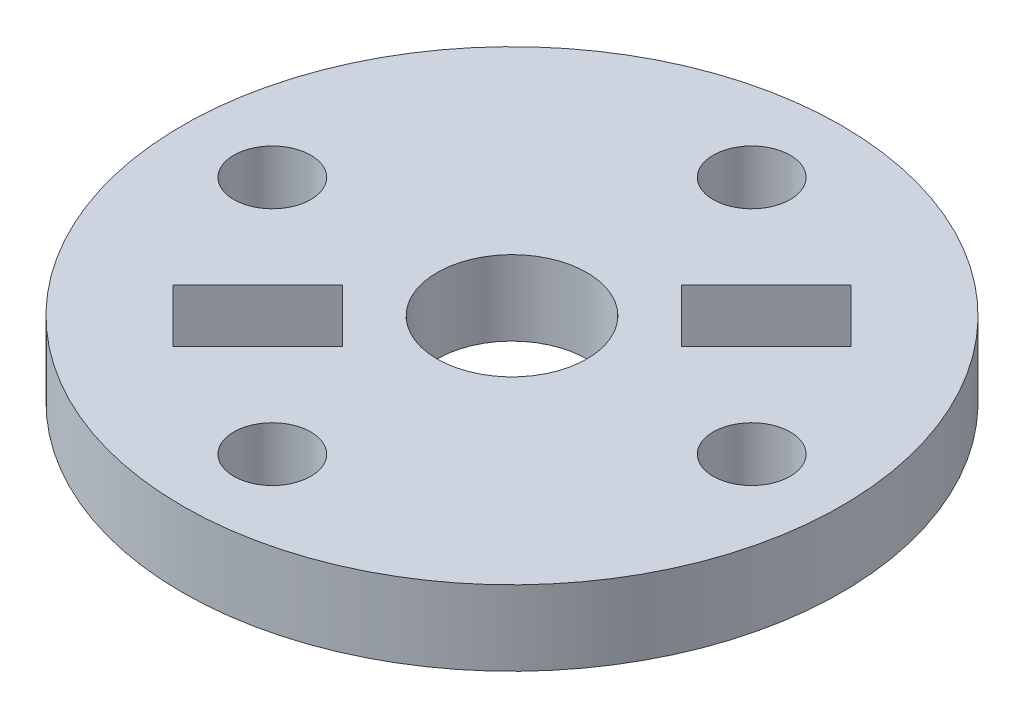
from build123d import *

# Parameters (mm, degrees)
SKETCH1_R           = 13.97
BOSS_EXTRUDE1_DEPTH = 3.175
SKETCH2_R           = 3.175
CUT_EXTRUDE1_DEPTH  = 3.175
CIRPATTERN1_COUNT   = 4
CUT_EXTRUDE2_DEPTH  = 5.08
CIRPATTERN2_COUNT   = 2


with BuildPart() as part:
    # Sketch1 → Boss-Extrude1 (new body)
    with BuildSketch(Plane(origin=(0, 0, 0), x_dir=(1, 0, 0), z_dir=(0, 1, 0))):
        Circle(SKETCH1_R)
    extrude(amount=BOSS_EXTRUDE1_DEPTH)

    # Sketch2 → Cut-Extrude1 (cut)
    with BuildSketch(Plane(origin=(0, 3.175, 0), x_dir=(1, 0, 0), z_dir=(0, 1, 0))):
        Circle(SKETCH2_R)
    extrude(amount=-CUT_EXTRUDE1_DEPTH, mode=Mode.SUBTRACT)

    # Sketch4 → #4 Clearance Hole1 (revolve, cut)
    with BuildSketch(Plane(origin=(0, 3.175, -10.16), x_dir=(0, 0, 1), z_dir=(1, 0, 0))):
        Polygon((0, 0), (0, 11.140574487), (1.63195, 10.16), (1.63195, 0), align=None)
    f_4_clearance_hole1 = revolve(axis=Axis((0, 9.525, -10.16), (0, -1, 0)), mode=Mode.SUBTRACT)

    # CirPattern1: #4 Clearance Hole1 ×4 about axis
    cirpattern1_axis = Axis((0, 0, 0), (0, 1, 0))
    for i in range(1, CIRPATTERN1_COUNT):
        add(f_4_clearance_hole1.rotate(cirpattern1_axis, i * 360 / CIRPATTERN1_COUNT), mode=Mode.SUBTRACT)

    # Sketch6 → Cut-Extrude2 (cut)
    with BuildSketch(Plane(origin=(0, 3.175, 0), x_dir=(1, 0, 0), z_dir=(0, 1, 0))):
        Polygon((4.714634464, 2.469570433), (8.306736912, 6.061672882), (6.061672882, 8.306736912), (2.469570433, 4.714634464), align=None)
    cut_extrude2 = extrude(amount=-CUT_EXTRUDE2_DEPTH, mode=Mode.SUBTRACT)

    # CirPattern2: Cut-Extrude2 ×2 about axis
    cirpattern2_axis = Axis((0, 0, 0), (0, 1, 0))
    for i in range(1, CIRPATTERN2_COUNT):
        add(cut_extrude2.rotate(cirpattern2_axis, i * 360 / CIRPATTERN2_COUNT), mode=Mode.SUBTRACT)


solid = part.part
